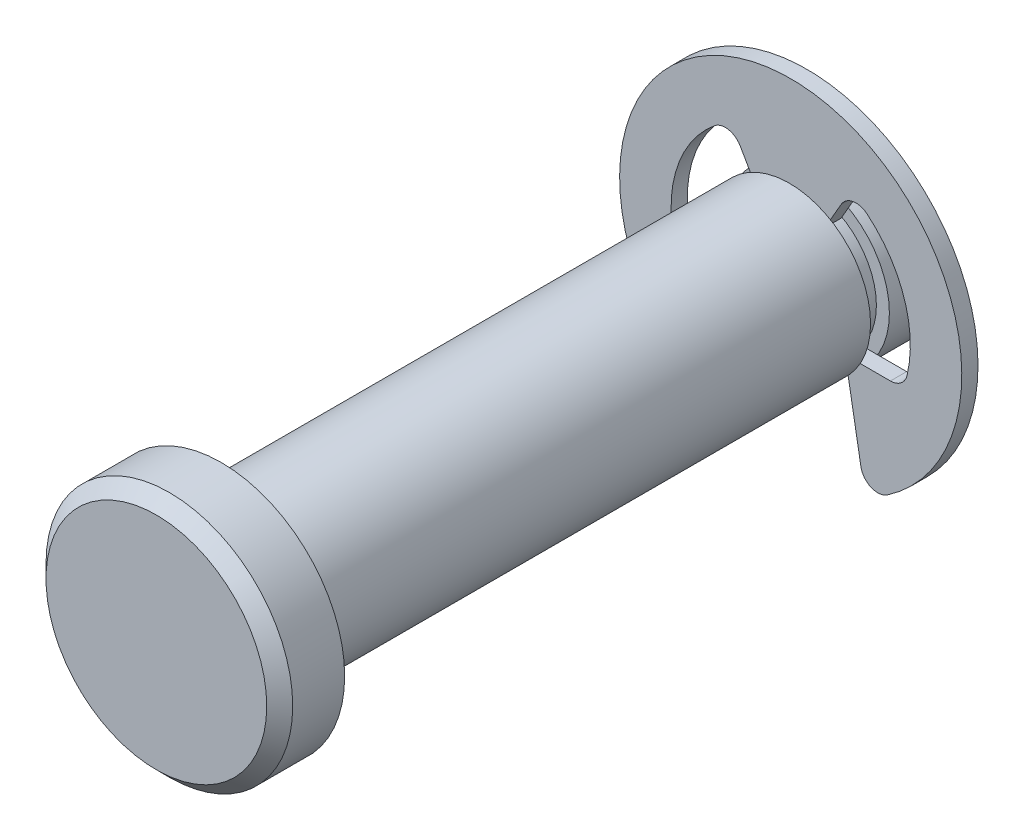
from build123d import *

# Parameters (mm, degrees)
SKETCH2_R      = 3.175
EXTRUDE1_DEPTH = 12.7
SKETCH3_W      = 0.7366
SKETCH3_H      = 0.508
SKETCH8_R      = 4.826
EXTRUDE6_DEPTH = 2.54
CHAMFER2_SIZE  = 0.508
SKETCH4_R      = 6.6929
SKETCH4_R_2    = 2.667
EXTRUDE2_DEPTH = 0.3175
EXTRUDE4_DEPTH = 13.7
EXTRUDE5_DEPTH = 0.635
FILLET1_R      = 0.66929
CHAMFER1_SIZE  = 0.635


with BuildPart() as part:
    # Sketch2 → Extrude1 (new body, symmetric)
    with BuildSketch(Plane.XY):
        Circle(SKETCH2_R)
    extrude(amount=EXTRUDE1_DEPTH, both=True)

    # Sketch3 → Cut-Revolve1 (revolve, cut)
    with BuildSketch(Plane(origin=(0, 0, 0), x_dir=(0, 0, -1), z_dir=(1, 0, 0))):
        with Locations((9.8933, 2.921)):
            Rectangle(SKETCH3_W, SKETCH3_H)
    revolve(axis=Axis((0, 0, 12.7), (0, 0, -1)), mode=Mode.SUBTRACT)

    # Sketch8 → Extrude6 (add)
    with BuildSketch(Plane.XY.offset(12.7)):
        Circle(SKETCH8_R)
    extrude(amount=EXTRUDE6_DEPTH)

    # Chamfer2
    chamfer2_edges = [part.edges().sort_by_distance(p)[0] for p in [
        (-4.826, 0, 15.24),
    ]]
    chamfer(chamfer2_edges, length=CHAMFER2_SIZE)

    # Chamfer1
    chamfer1_edges = [part.edges().sort_by_distance(p)[0] for p in [
        (-3.175, 0, -12.7),
    ]]
    chamfer(chamfer1_edges, length=CHAMFER1_SIZE)


with BuildPart() as body_2:
    # Sketch4 → Extrude2 (new body, symmetric)
    with BuildSketch(Plane.XY.offset(-9.8933)):
        Circle(SKETCH4_R)
        Circle(SKETCH4_R_2, mode=Mode.SUBTRACT)
    extrude(amount=EXTRUDE2_DEPTH, both=True)

    # Sketch5 → Extrude4 (cut, through all)
    with BuildSketch(Plane.XY):
        with BuildLine():
            Line((-2.339975, 4.052955588), (0, 0))
            Line((0, 0), (2.339975, 4.052955588))
            ThreePointArc((2.339975, 4.052955588), (4.397634918, 1.600855749), (4.397873573, -1.6002))
            Line((4.397873573, -1.6002), (2.1336, -1.6002))
            Line((2.1336, -1.6002), (2.913865383, -6.025304883))
            ThreePointArc((2.913865383, -6.025304883), (0, -6.6929), (-2.913865383, -6.025304883))
            Line((-2.913865383, -6.025304883), (-2.1336, -1.6002))
            Line((-2.1336, -1.6002), (-4.397873573, -1.6002))
            ThreePointArc((-4.397873573, -1.6002), (-4.397634918, 1.600855749), (-2.339975, 4.052955588))
        make_face()
    extrude(amount=-EXTRUDE4_DEPTH, mode=Mode.SUBTRACT)

    # Sketch6 → Extrude5 (add)
    with BuildSketch(Plane.XY.offset(-9.5758)):
        with BuildLine():
            Line((-1.3335, 2.309689752), (1.3335, 2.309689752))
            ThreePointArc((1.3335, 2.309689752), (0, 2.667), (-1.3335, 2.309689752))
        make_face()
    extrude(amount=-EXTRUDE5_DEPTH)

    # Fillet1
    fillet1_edges = [body_2.edges().sort_by_distance(p)[0] for p in [
        (2.339975, 4.052955588, -9.8933),
        (2.913865383, -6.025304883, -9.8933),
        (-4.397873573, -1.6002, -9.8933),
        (4.397873573, -1.6002, -9.8933),
        (-2.913865383, -6.025304883, -9.8933),
        (-2.339975, 4.052955588, -9.8933),
    ]]
    fillet(fillet1_edges, radius=FILLET1_R)


solid = Compound([part.part, body_2.part])
